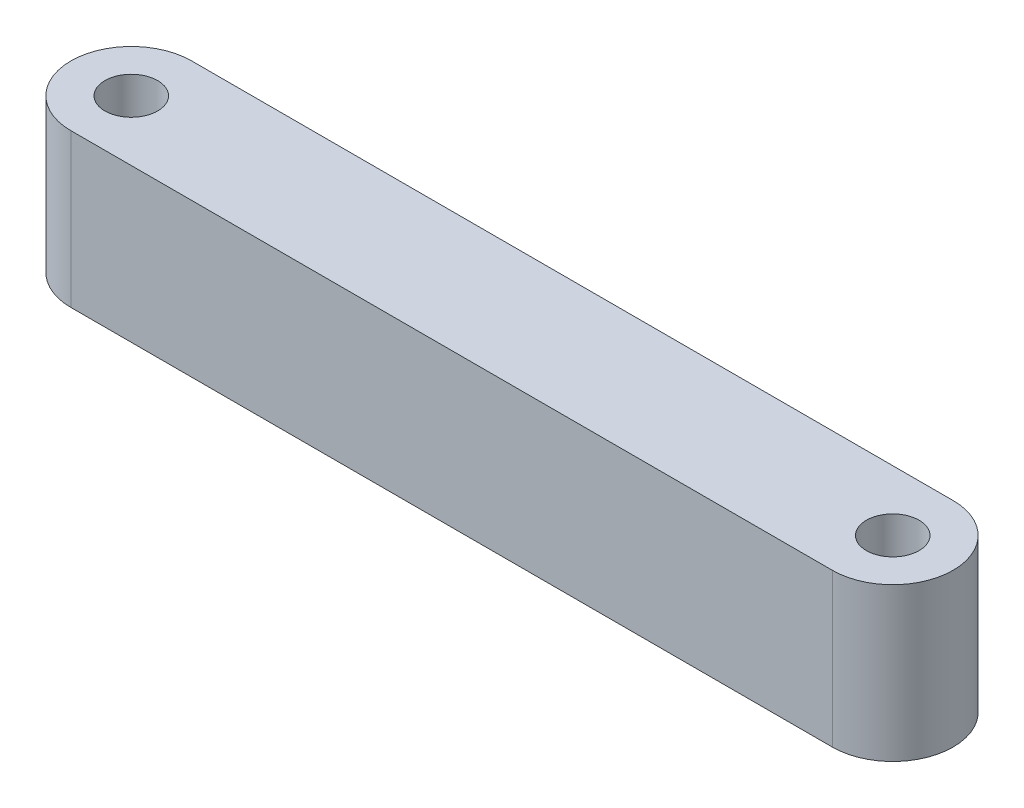
from build123d import *

# Parameters (mm, degrees)
SKETCH1_R           = 1.55
BOSS_EXTRUDE1_DEPTH = 9


with BuildPart() as part:
    # Sketch1 → Boss-Extrude1 (new body)
    with BuildSketch(Plane(origin=(0, 0, 0), x_dir=(1, 0, 0), z_dir=(0, 1, 0))):
        with BuildLine():
            Line((-22.944975122, 3.55), (21.810024878, 3.55))
            ThreePointArc((21.810024878, 3.55), (25.360024878, 0), (21.810024878, -3.55))
            Line((21.810024878, -3.55), (-22.944975122, -3.55))
            ThreePointArc((-22.944975122, -3.55), (-26.494975122, 0), (-22.944975122, 3.55))
        make_face()
        with Locations((-22.944975122, 0)):
            Circle(SKETCH1_R, mode=Mode.SUBTRACT)
        with Locations((21.810024878, 0)):
            Circle(SKETCH1_R, mode=Mode.SUBTRACT)
    extrude(amount=BOSS_EXTRUDE1_DEPTH)


solid = part.part
